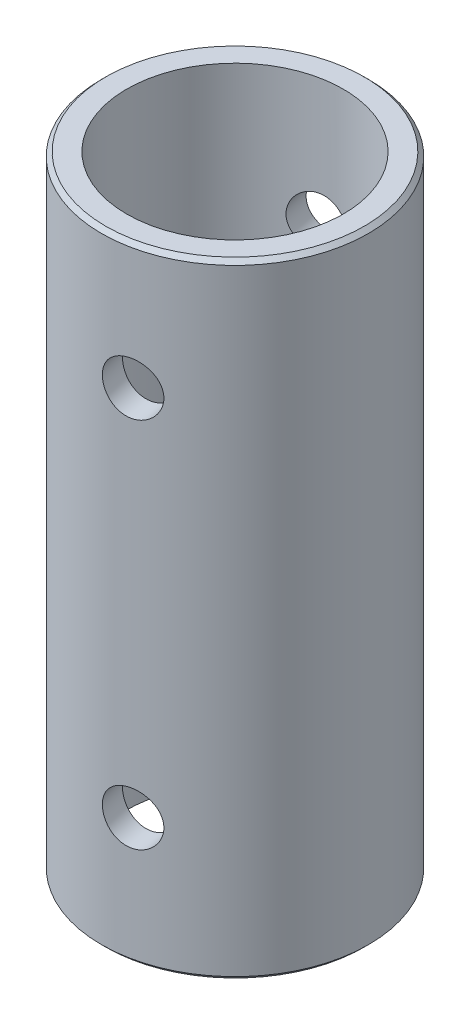
from build123d import *

# Parameters (mm, degrees)
SKETCH1_R               = 7.94
SKETCH1_R_2             = 6.44
BOSS_EXTRUDE1_DEPTH     = 37.13
CHAMFER1_SIZE           = 0.25
SKETCH2_R               = 1.55
CUT_EXTRUDE1_DEPTH      = 41.603627037
CUT_EXTRUDE1_DEPTH_BACK = 41.603627037


with BuildPart() as part:
    # Sketch1 → Boss-Extrude1 (new body)
    with BuildSketch(Plane(origin=(0, 0, 0), x_dir=(1, 0, 0), z_dir=(0, 1, 0))):
        with Locations(Location((0, 0, 0), (0, 0, 270))):
            Circle(SKETCH1_R)
        with Locations(Location((0, 0, 0), (0, 0, 270))):
            Circle(SKETCH1_R_2, mode=Mode.SUBTRACT)
    extrude(amount=BOSS_EXTRUDE1_DEPTH)

    # Chamfer1
    chamfer1_edges = [part.edges().sort_by_distance(p)[0] for p in [
        (0, 0, -7.94),
        (0, 37.13, -7.94),
    ]]
    chamfer(chamfer1_edges, length=CHAMFER1_SIZE)

    # Sketch2 → Cut-Extrude1 (cut, two sides)
    with BuildSketch(Plane(origin=(-1.178494154, 0, -5.730065578), x_dir=(-0.9794983894003966, 0, 0.2014519922016887), z_dir=(-0.20145199220168866, 0, -0.9794983894003965))) as cut_extrude1_sk:
        with Locations((0, 7.5)):
            Circle(SKETCH2_R)
        with BuildLine():
            add(Edge.make_bspline(
                [(0.577058583, 28.191501993), (3.454054595, 29.346012251), (2.299544337, 32.223008265), (-0.577451675, 31.068498007), (-3.454447687, 29.913987749), (-2.29993743, 27.036991735), (0.577058583, 28.191501993)],
                knots=[0, 0, 0, 0, 0.5, 0.5, 0.5, 1, 1, 1, 1], degree=3, weights=[1, 0.333333333, 0.333333333, 1, 0.333333333, 0.333333333, 1]))
        make_face()
    extrude(amount=CUT_EXTRUDE1_DEPTH, mode=Mode.SUBTRACT)
    extrude(cut_extrude1_sk.sketch, amount=-CUT_EXTRUDE1_DEPTH_BACK, mode=Mode.SUBTRACT)


solid = part.part
